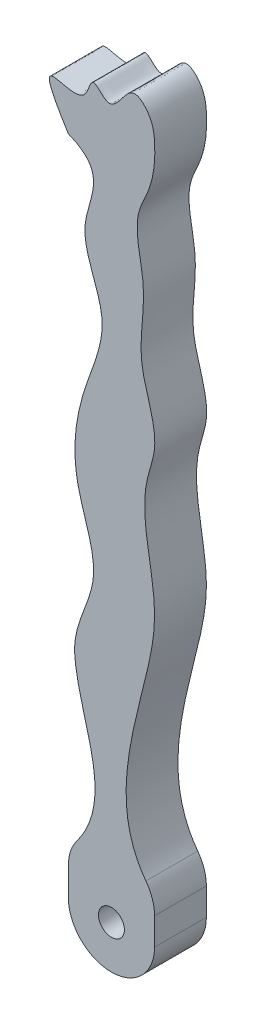
from build123d import *

# Parameters (mm, degrees)
SKETCH1_R           = 1.5
BOSS_EXTRUDE1_DEPTH = 6
SKETCH3_W           = 6
SKETCH3_H           = 19.728320027
SKETCH3_H_2         = 60.271679973
BOSS_EXTRUDE2_DEPTH = 10
SKETCH4_W           = 9.051057065
SKETCH4_H           = 6
CUT_EXTRUDE1_DEPTH  = 162
SKETCH5_W           = 2.776805371
SKETCH5_H           = 7.673994378
CUT_EXTRUDE2_DEPTH  = 162
BOSS_EXTRUDE5_DEPTH = 6
CUT_EXTRUDE6_DEPTH  = 6
CUT_EXTRUDE7_DEPTH  = 6
FILLET1_R           = 5


with BuildPart() as part:
    # Sketch1 → Boss-Extrude1 (new body)
    with BuildSketch(Plane.XY):
        with BuildLine():
            Line((0, 0), (0, -9.98))
            Line((0, -9.98), (9.98, -9.98))
            Line((9.98, -9.98), (9.98, 0))
            add(Edge.make_bspline(
                [(0, 54.250736404), (-1.3001908, 57.732186027), (3.264697289, 54.364229546), (2.426320397, 59.671317952), (6.24965715, 57.931332096), (7.559999273, 60.308317398), (10.808963849, 60.427698471), (10.337139395, 56.901907174), (8.667893464, 54.394927102), (7.624843251, 50.040394793), (9.267984866, 44.554889548), (7.046090887, 37.973638675), (9.84685356, 30.217018819), (6.270285073, 21.673277978), (10.793667439, 11.106885954), (4.474903421, 3.416500301), (9.98, 0)],
                knots=[0, 0, 0, 0, 0.053422047, 0.084053188, 0.123826292, 0.153487584, 0.181182143, 0.220513, 0.254555574, 0.310198036, 0.38825613, 0.476667751, 0.573339812, 0.700293064, 0.81918735, 1, 1, 1, 1], degree=3))
            add(Edge.make_bspline(
                [(0, 54.250736404), (5.084395927, 51.698919308), (-1.040481835, 45.991903649), (5.447322124, 39.887247803), (0.909066537, 34.169036482), (6.005419265, 27.503354662), (0.487031558, 20.054851145), (5.671743487, 12.84454135), (0.403542473, 6.211235786), (5.177057559, 1.35031129), (0, 0)],
                knots=[0, 0, 0, 0, 0.175024795, 0.269809775, 0.365352016, 0.476782251, 0.63395402, 0.755982767, 0.862891176, 1, 1, 1, 1], degree=3))
        make_face()
        with Locations((4.99, -4.99)):
            Circle(SKETCH1_R, mode=Mode.SUBTRACT)
    extrude(amount=BOSS_EXTRUDE1_DEPTH)

    # Sketch3 → Boss-Extrude2 (add)
    with BuildSketch(Plane.ZY):
        with Locations((3, 70.135839987)):
            Rectangle(SKETCH3_W, SKETCH3_H)
        with Locations((3, 30.135839987)):
            Rectangle(SKETCH3_W, SKETCH3_H_2)
    extrude(amount=-BOSS_EXTRUDE2_DEPTH)

    # Sketch4 → Cut-Extrude1 (cut)
    with BuildSketch(Plane.XZ):
        with Locations((14.505528533, 3)):
            Rectangle(SKETCH4_W, SKETCH4_H)
    extrude(amount=-CUT_EXTRUDE1_DEPTH, mode=Mode.SUBTRACT)

    # Sketch5 → Cut-Extrude2 (cut)
    with BuildSketch(Plane.XZ.offset(9.98)):
        with Locations((-1.388402686, 2.163002811)):
            Rectangle(SKETCH5_W, SKETCH5_H)
    extrude(amount=-CUT_EXTRUDE2_DEPTH, mode=Mode.SUBTRACT)

    # Sketch6 → Boss-Extrude5 (add)
    with BuildSketch(Plane.XY.offset(6)):
        with BuildLine():
            Line((0, 0), (9.98, 0))
            add(Edge.make_bspline(
                [(0, 71.565015572), (-5.233481071, 79.907611656), (1.768615813, 73.094871264), (2.670286929, 79.156877028), (5.223042931, 75.326632847), (6.956306721, 80.779428566), (9.72377383, 77.996098239), (10.160057246, 74.896042147), (9.844837038, 71.201088951), (7.188888223, 66.637436911), (9.4931909, 60.369196515), (7.470940633, 52.801771701), (10.892557693, 46.328259673), (7.679484936, 38.427753022), (10.960776938, 30.127397364), (7.841955695, 16.603957566), (4.622500467, 5.401412431), (9.98, 0)],
                knots=[0, 0, 0, 0, 0.0748046, 0.094365624, 0.114748154, 0.154560578, 0.178597201, 0.202324023, 0.255569531, 0.288547505, 0.360702051, 0.443388282, 0.525057154, 0.564586383, 0.697373731, 0.776283322, 1, 1, 1, 1], degree=3))
            add(Edge.make_bspline(
                [(0, 71.565015572), (4.953798742, 69.587898657), (-0.349346036, 63.492834601), (5.467474092, 55.145566135), (1.272427541, 46.575024936), (-0.016634013, 37.476434717), (4.509087779, 28.782291309), (0.375030838, 22.622259726), (1.488936723, 12.725606575), (5.63606806, 6.031245879), (0, 0)],
                knots=[0, 0, 0, 0, 0.126258819, 0.238720386, 0.351181954, 0.484025061, 0.603344795, 0.708762826, 0.74907921, 1, 1, 1, 1], degree=3))
        make_face()
    extrude(amount=-BOSS_EXTRUDE5_DEPTH)

    # Sketch8 → Cut-Extrude6 (cut)
    with BuildSketch(Plane.XY):
        with BuildLine():
            Line((0, 71.565015572), (0, 0))
            add(Edge.make_bspline(
                [(0, 71.565015572), (4.953798742, 69.587898657), (-0.349346036, 63.492834601), (5.467474092, 55.145566135), (1.272427541, 46.575024936), (-0.016634013, 37.476434717), (4.509087779, 28.782291309), (0.375030838, 22.622259726), (1.488936723, 12.725606575), (5.63606806, 6.031245879), (0, 0)],
                knots=[0, 0, 0, 0, 0.126258819, 0.238720386, 0.351181954, 0.484025061, 0.603344795, 0.708762826, 0.74907921, 1, 1, 1, 1], degree=3))
        make_face()
        with BuildLine():
            add(Edge.make_bspline(
                [(9.98, 28.13204565), (9.952286847, 25.754989067), (7.799504274, 16.456241902), (4.622500467, 5.401412431), (9.98, 0)],
                knots=[0.701364132, 0.701364132, 0.701364132, 0.701364132, 0.776283322, 1, 1, 1, 1], degree=3))
            Line((9.98, 0), (9.98, 28.13204565))
        make_face()
        with BuildLine():
            Line((0, 80), (0, 76.103761554))
            add(Edge.make_bspline(
                [(0, 76.103761554), (0.73790192, 75.973787116), (2.193773206, 75.953237826), (2.670286929, 79.156877028), (5.223042931, 75.326632847), (6.956306721, 80.779428566), (9.72377383, 77.996098239), (9.930076325, 76.530194923), (9.98, 75.780679225)],
                knots=[0.054106232, 0.054106232, 0.054106232, 0.054106232, 0.0748046, 0.094365624, 0.114748154, 0.154560578, 0.178597201, 0.202324023, 0.202324023, 0.202324023, 0.202324023], degree=3))
            Line((9.98, 75.780679225), (9.98, 80))
            Line((9.98, 80), (0, 80))
        make_face()
        with BuildLine():
            add(Edge.make_bspline(
                [(9.98, 45.02577082), (9.859396039, 43.787856411), (7.679484936, 38.427753022), (9.930130292, 32.734520935), (9.98, 28.512271334)],
                knots=[0.525057154, 0.525057154, 0.525057154, 0.525057154, 0.564586383, 0.697373731, 0.697373731, 0.697373731, 0.697373731], degree=3))
            Line((9.98, 28.512271334), (9.98, 45.02577082))
        make_face()
        with BuildLine():
            Line((9.98, 46.329125975), (9.98, 73.795111706))
            add(Edge.make_bspline(
                [(9.98, 73.795111706), (9.905431817, 72.737394524), (9.499299822, 70.607360784), (7.188888223, 66.637436911), (9.4931909, 60.369196515), (7.589292932, 53.244655618), (9.794114993, 48.462609975), (9.98, 46.329125975)],
                knots=[0.222928902, 0.222928902, 0.222928902, 0.222928902, 0.255569531, 0.288547505, 0.360702051, 0.443388282, 0.511215415, 0.511215415, 0.511215415, 0.511215415], degree=3))
        make_face()
    extrude(amount=CUT_EXTRUDE6_DEPTH, mode=Mode.SUBTRACT)

    # Sketch9 → Cut-Extrude7 (cut)
    with BuildSketch(Plane.XY.offset(6)):
        with BuildLine():
            Line((0, -9.98), (4.99, -9.98))
            ThreePointArc((4.99, -9.98), (1.461537162, -8.518462838), (0, -4.99))
            Line((0, -4.99), (0, -9.98))
        make_face()
        with BuildLine():
            Line((4.99, -9.98), (9.98, -9.98))
            Line((9.98, -9.98), (9.98, -4.99))
            ThreePointArc((9.98, -4.99), (8.518462838, -8.518462838), (4.99, -9.98))
        make_face()
    extrude(amount=-CUT_EXTRUDE7_DEPTH, mode=Mode.SUBTRACT)

    # Fillet1
    fillet1_edges = [part.edges().sort_by_distance(p)[0] for p in [
        (0, 0, 3),
        (9.98, 0, 3),
    ]]
    fillet(fillet1_edges, radius=FILLET1_R)


solid = part.part
